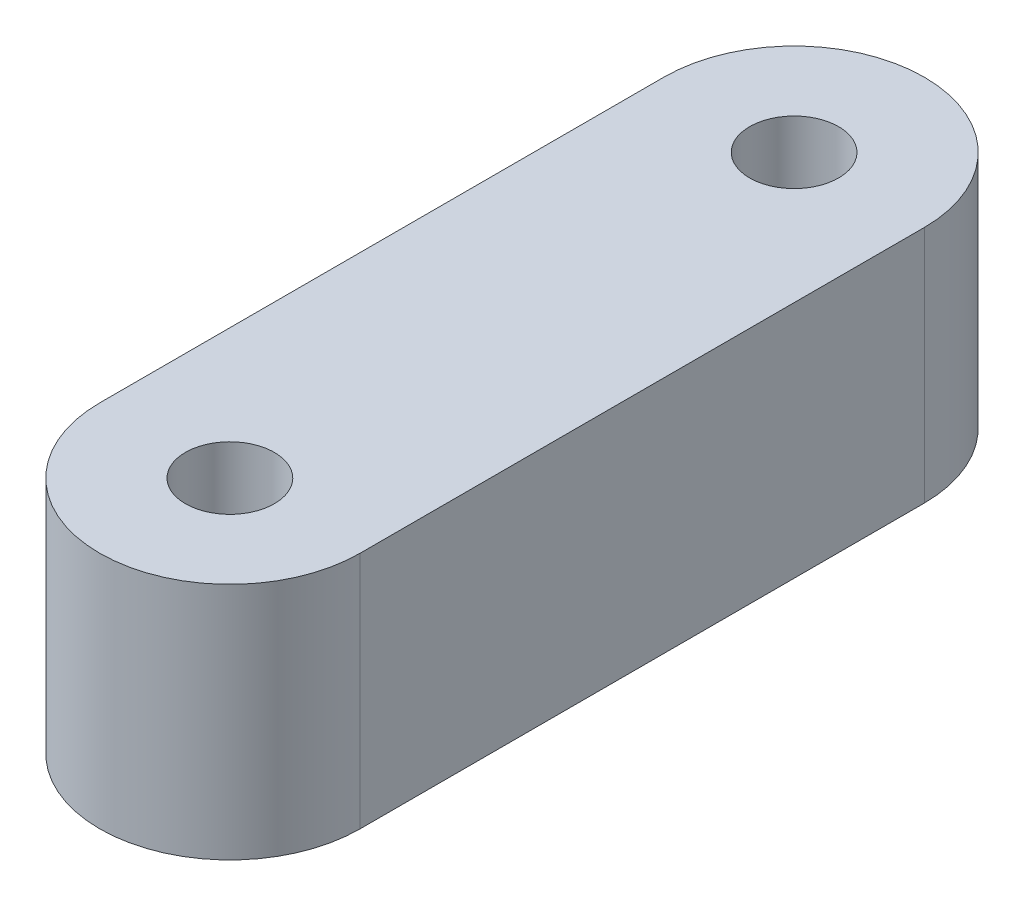
from build123d import *

# Parameters (mm, degrees)
EXTRUDE_1_DEPTH     = 11
SKETCH_2_R          = 2.05
CUT_EXTRUDE_1_DEPTH = 12
SKETCH_3_R          = 3.1
CUT_EXTRUDE_2_DEPTH = 10


with BuildPart() as part:
    # 草图1 → 凸台-拉伸1 (new body)
    with BuildSketch(Plane(origin=(0, 0, 0), x_dir=(1, 0, 0), z_dir=(0, 1, 0))):
        with BuildLine():
            Line((-6, -13), (-6, 13))
            ThreePointArc((-6, 13), (0, 19), (6, 13))
            Line((6, 13), (6, -13))
            ThreePointArc((6, -13), (0, -19), (-6, -13))
        make_face()
    extrude(amount=EXTRUDE_1_DEPTH)

    # 草图2 → 切除-拉伸1 (cut, through all)
    with BuildSketch(Plane(origin=(0, 11, 0), x_dir=(1, 0, 0), z_dir=(0, 1, 0))):
        with Locations((0, 13)):
            Circle(SKETCH_2_R)
        with Locations((0, -13)):
            Circle(SKETCH_2_R)
    extrude(amount=-CUT_EXTRUDE_1_DEPTH, mode=Mode.SUBTRACT)

    # 草图3 → 切除-拉伸2 (cut)
    with BuildSketch(Plane.ZY.offset(6)):
        with Locations((0, 5.5)):
            Circle(SKETCH_3_R)
    extrude(amount=-CUT_EXTRUDE_2_DEPTH, mode=Mode.SUBTRACT)


solid = part.part
